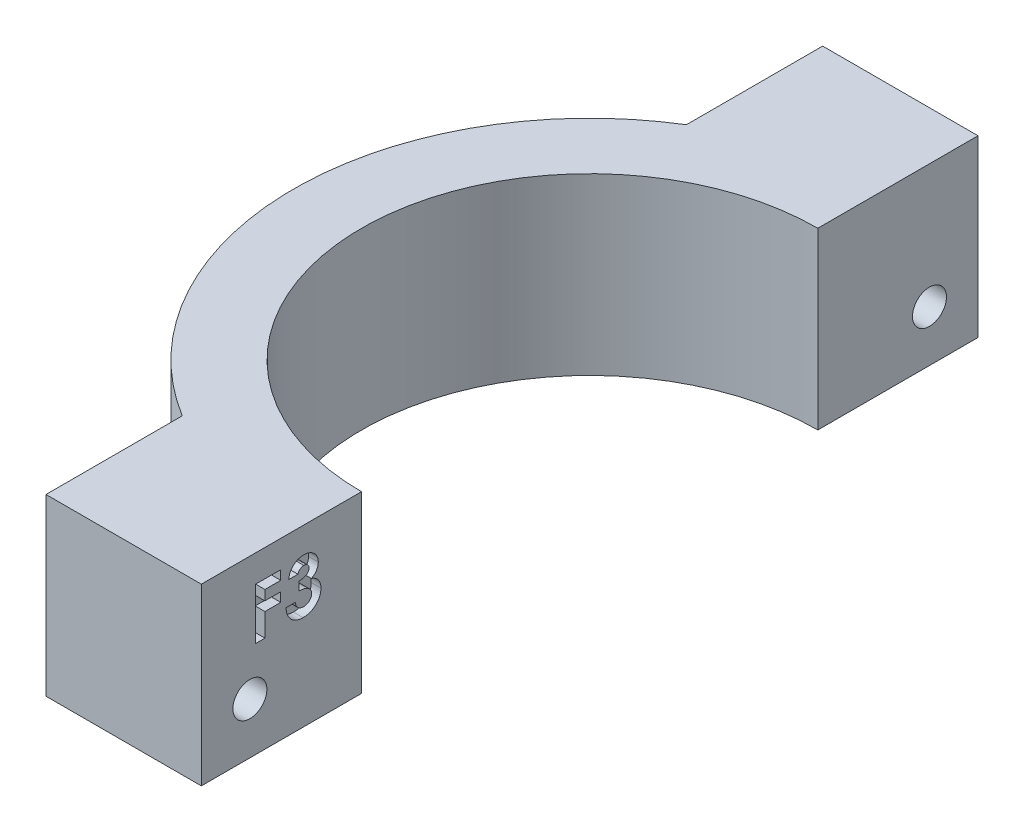
from build123d import *

# Parameters (mm, degrees)
BOSS_EXTRUDE1_DEPTH = 18
SKETCH2_R           = 1.75
CUT_EXTRUDE1_DEPTH  = 31.5
CUT_EXTRUDE2_DEPTH  = 1
CUT_EXTRUDE3_DEPTH  = 5


with BuildPart() as part:
    # Sketch1 → Boss-Extrude1 (new body)
    with BuildSketch(Plane(origin=(0, 0, 0), x_dir=(1, 0, 0), z_dir=(0, 1, 0))):
        with BuildLine():
            Line((-16.998275301, 32.528571429), (-32.998275301, 32.528571429))
            Line((-32.998275301, 32.528571429), (-32.998275301, 18.494895774))
            ThreePointArc((-32.998275301, 18.494895774), (-47.498275301, -7.471428571), (-32.998275301, -33.437752917))
            Line((-32.998275301, -33.437752917), (-32.998275301, -47.471428571))
            Line((-32.998275301, -47.471428571), (-16.998275301, -47.471428571))
            Line((-16.998275301, -47.471428571), (-16.998275301, -30.971428571))
            ThreePointArc((-16.998275301, -30.971428571), (-40.498275301, -7.471428571), (-16.998275301, 16.028571429))
            Line((-16.998275301, 16.028571429), (-16.998275301, 32.528571429))
        make_face()
    extrude(amount=BOSS_EXTRUDE1_DEPTH)

    # Sketch2 → Cut-Extrude1 (cut, through all)
    with BuildSketch(Plane(origin=(-16.998275301, 0, 0), x_dir=(0, 0, -1), z_dir=(1, 0, 0))):
        with Locations((-42.471428571, 5.25)):
            Circle(SKETCH2_R)
        with Locations((27.528571429, 5.25)):
            Circle(SKETCH2_R)
    extrude(amount=-CUT_EXTRUDE1_DEPTH, mode=Mode.SUBTRACT)

    # Sketch3 → Cut-Extrude2 (cut)
    with BuildSketch(Plane(origin=(-16.998275301, 0, 0), x_dir=(0, 0, -1), z_dir=(1, 0, 0))):
        Polygon((-41.871148795, 15.201025034), (-39.293157342, 15.201025034), (-39.293157342, 14.251238709), (-40.92136247, 14.251238709), (-40.92136247, 13.233610504), (-39.293157342, 13.233610504), (-39.293157342, 12.283824179), (-40.92136247, 12.283824179), (-40.92136247, 9.909358367), (-41.871148795, 9.909358367), align=None)
        with BuildLine():
            Line((-37.529268453, 13.912029308), (-38.479054777, 13.912029308))
            add(Edge.make_bspline(
                [(-38.479054777, 13.912029308), (-38.472348925, 13.959505738), (-38.459202545, 14.052580134), (-38.427745016, 14.187328674), (-38.390118416, 14.315146885), (-38.34314353, 14.435629995), (-38.288049629, 14.548992623), (-38.225396959, 14.655623774), (-38.154508221, 14.755065768), (-38.100171252, 14.814970019), (-38.073063525, 14.844855162)],
                knots=[0, 0, 0, 0, 0.000143778, 0.000281867, 0.000414671, 0.000543215, 0.000669322, 0.0007924, 0.000913902, 0.001034861, 0.001034861, 0.001034861, 0.001034861], degree=3))
            add(Edge.make_bspline(
                [(-38.073063525, 14.844855162), (-38.033964221, 14.884286443), (-37.956903602, 14.962001353), (-37.82812627, 15.061545568), (-37.693143844, 15.147694317), (-37.549249192, 15.215993668), (-37.398681424, 15.27127408), (-37.240243172, 15.308406058), (-37.074581872, 15.333043453), (-36.961538875, 15.335470322), (-36.903851118, 15.336708795)],
                knots=[0, 0, 0, 0, 0.000166428, 0.000328012, 0.000487119, 0.000645947, 0.000804887, 0.000967376, 0.001133328, 0.001306272, 0.001306272, 0.001306272, 0.001306272], degree=3))
            add(Edge.make_bspline(
                [(-36.903851118, 15.336708795), (-36.852563734, 15.335498), (-36.751743072, 15.333117822), (-36.603562067, 15.314011042), (-36.462283879, 15.280499879), (-36.326415158, 15.236684784), (-36.197954088, 15.177067025), (-36.07406541, 15.107863497), (-35.958210577, 15.022982493), (-35.850118512, 14.927075501), (-35.750815335, 14.8233427), (-35.664818348, 14.712460867), (-35.590885195, 14.597391911), (-35.529974057, 14.477179826), (-35.483141668, 14.3516212), (-35.450638602, 14.221441367), (-35.429364556, 14.08692758), (-35.427245105, 13.99550037), (-35.426170162, 13.949130336)],
                knots=[0, 0, 0, 0, 0.000153836, 0.00030241, 0.000447173, 0.000588968, 0.00072986, 0.000871333, 0.001014032, 0.001159723, 0.001304436, 0.001444171, 0.001580024, 0.001714184, 0.00184768, 0.001981114, 0.002116187, 0.002255197, 0.002255197, 0.002255197, 0.002255197], degree=3))
            add(Edge.make_bspline(
                [(-35.426170162, 13.949130336), (-35.428376009, 13.89170491), (-35.432718642, 13.778651902), (-35.468353097, 13.613190424), (-35.524130708, 13.454979724), (-35.604706892, 13.306233407), (-35.705447645, 13.167356277), (-35.829053175, 13.042991412), (-35.972002875, 12.931188942), (-36.079317119, 12.87110628), (-36.134269788, 12.840339604)],
                knots=[0, 0, 0, 0, 0.00017212, 0.000338852, 0.000505492, 0.00067385, 0.000844528, 0.001018431, 0.001198237, 0.00138694, 0.00138694, 0.00138694, 0.00138694], degree=3))
            add(Edge.make_bspline(
                [(-36.134269788, 12.840339604), (-36.096551119, 12.827955771), (-36.022435626, 12.803622094), (-35.917089364, 12.755697192), (-35.816917106, 12.703323219), (-35.723643783, 12.642478468), (-35.636341679, 12.575623232), (-35.555542998, 12.502186007), (-35.480764986, 12.422326922), (-35.413228364, 12.335606781), (-35.353286974, 12.243412505), (-35.299504756, 12.147873726), (-35.255238993, 12.047541582), (-35.21774038, 11.943561934), (-35.189191072, 11.835000267), (-35.169089807, 11.722277248), (-35.157470783, 11.605650007), (-35.155698684, 11.526635122), (-35.154802641, 11.486682085)],
                knots=[0, 0, 0, 0, 0.000119012, 0.000233852, 0.000346714, 0.000457856, 0.00056747, 0.000676282, 0.000785032, 0.000895296, 0.001005549, 0.001114686, 0.001223822, 0.001334132, 0.001445978, 0.001560132, 0.001677317, 0.001797176, 0.001797176, 0.001797176, 0.001797176], degree=3))
            add(Edge.make_bspline(
                [(-35.154802641, 11.486682085), (-35.156619041, 11.427967343), (-35.160200611, 11.31219383), (-35.182970562, 11.141671293), (-35.225364107, 10.979093204), (-35.281135164, 10.822588857), (-35.355527701, 10.674178666), (-35.443075211, 10.53045682), (-35.55068869, 10.396407552), (-35.670282595, 10.268486948), (-35.803098598, 10.152187262), (-35.947092752, 10.051360668), (-36.09909875, 9.964833512), (-36.260078289, 9.8945883), (-36.429975443, 9.840491454), (-36.608411526, 9.801387759), (-36.796136276, 9.777463472), (-36.924273105, 9.774955464), (-36.989713498, 9.773674607)],
                knots=[0, 0, 0, 0, 0.000176169, 0.00034737, 0.00051474, 0.000679386, 0.000844836, 0.001011921, 0.001183269, 0.001359492, 0.001536793, 0.001711778, 0.001885991, 0.002060677, 0.00223768, 0.002420033, 0.00260805, 0.002804296, 0.002804296, 0.002804296, 0.002804296], degree=3))
            add(Edge.make_bspline(
                [(-36.989713498, 9.773674607), (-37.051619054, 9.775025054), (-37.172667177, 9.777665676), (-37.349725391, 9.800521596), (-37.518002464, 9.837390049), (-37.677927841, 9.889359191), (-37.828882784, 9.956754287), (-37.972236212, 10.037006724), (-38.105127537, 10.134745277), (-38.229037432, 10.245557842), (-38.341217201, 10.369883248), (-38.441479496, 10.504841559), (-38.527613517, 10.650945966), (-38.599972501, 10.80757225), (-38.657990763, 10.974995181), (-38.703755398, 11.152874295), (-38.735722744, 11.341557113), (-38.745458467, 11.471374906), (-38.750422299, 11.537563496)],
                knots=[0, 0, 0, 0, 0.000185653, 0.000363021, 0.000534566, 0.000701839, 0.000866512, 0.001029812, 0.001193709, 0.001360353, 0.001527707, 0.001695195, 0.001863902, 0.002035591, 0.002211932, 0.002394731, 0.002586078, 0.002785121, 0.002785121, 0.002785121, 0.002785121], degree=3))
            Line((-38.750422299, 11.537563496), (-37.800635974, 11.537563496))
            add(Edge.make_bspline(
                [(-37.800635974, 11.537563496), (-37.794617277, 11.504283004), (-37.782894287, 11.439460519), (-37.760029312, 11.345611971), (-37.730233061, 11.258983964), (-37.695781181, 11.178806552), (-37.658567964, 11.104027033), (-37.613605499, 11.037407199), (-37.564188399, 10.977138049), (-37.492879164, 10.905489419), (-37.3909377, 10.831873443), (-37.253282951, 10.767897658), (-37.100155079, 10.730399988), (-36.993103425, 10.725825387), (-36.937772058, 10.723460932)],
                knots=[0, 0, 0, 0, 0.000101453, 0.000197607, 0.000289457, 0.000375893, 0.000459333, 0.000539595, 0.000616416, 0.00069287, 0.00084235, 0.000990791, 0.001145821, 0.001311674, 0.001311674, 0.001311674, 0.001311674], degree=3))
            add(Edge.make_bspline(
                [(-36.937772058, 10.723460932), (-36.90841128, 10.72396442), (-36.850900082, 10.724950642), (-36.766424697, 10.735881586), (-36.685949998, 10.753884861), (-36.609326097, 10.778350644), (-36.536065202, 10.809020032), (-36.467567036, 10.848566373), (-36.402435434, 10.89454464), (-36.341378437, 10.946236417), (-36.284960514, 11.002561951), (-36.238017483, 11.06493291), (-36.19511495, 11.128312952), (-36.163383928, 11.196848623), (-36.135580716, 11.266851971), (-36.11856373, 11.340863899), (-36.105714684, 11.417331835), (-36.104967949, 11.469663134), (-36.104588966, 11.49622235)],
                knots=[0, 0, 0, 0, 8.804e-05, 0.00017245, 0.000255004, 0.000335125, 0.000413489, 0.000492771, 0.000571884, 0.000652369, 0.000732575, 0.000810392, 0.000886249, 0.00096163, 0.001036443, 0.001111772, 0.00118898, 0.001268546, 0.001268546, 0.001268546, 0.001268546], degree=3))
            add(Edge.make_bspline(
                [(-36.104588966, 11.49622235), (-36.105595096, 11.525269377), (-36.10759807, 11.583095353), (-36.123962582, 11.667480206), (-36.149805605, 11.748651634), (-36.18570472, 11.82625017), (-36.233643988, 11.899989803), (-36.290211789, 11.971349973), (-36.35986473, 12.036616511), (-36.436283336, 12.101130505), (-36.524898897, 12.15736725), (-36.621395711, 12.209265504), (-36.728309865, 12.250560491), (-36.843031489, 12.287444563), (-36.967730649, 12.314384117), (-37.101633011, 12.333944858), (-37.244522568, 12.348504799), (-37.343018198, 12.350593662), (-37.393584692, 12.35166606)],
                knots=[0, 0, 0, 0, 8.7084e-05, 0.000173364, 0.000256838, 0.000342201, 0.000428949, 0.000520167, 0.000614623, 0.000714788, 0.000819753, 0.000928812, 0.001042981, 0.001163003, 0.001290052, 0.001425126, 0.001568892, 0.001720568, 0.001720568, 0.001720568, 0.001720568], degree=3))
            Line((-37.393584692, 12.35166606), (-37.393584692, 13.233610504))
            add(Edge.make_bspline(
                [(-37.393584692, 13.233610504), (-37.330626399, 13.238972234), (-37.212843901, 13.249002968), (-37.049355478, 13.272460189), (-36.911719301, 13.303814627), (-36.796627281, 13.34164206), (-36.701062242, 13.390222338), (-36.617577152, 13.44385282), (-36.545675843, 13.506136787), (-36.484909592, 13.57521694), (-36.436298482, 13.649402546), (-36.40189437, 13.727540541), (-36.379175692, 13.80721324), (-36.377023099, 13.861706965), (-36.375956487, 13.888708661)],
                knots=[0, 0, 0, 0, 0.000189544, 0.000354599, 0.000494992, 0.000612655, 0.000716948, 0.000815736, 0.000909673, 0.001001315, 0.001090992, 0.001174513, 0.001256793, 0.001337606, 0.001337606, 0.001337606, 0.001337606], degree=3))
            add(Edge.make_bspline(
                [(-36.375956487, 13.888708661), (-36.377796698, 13.923159894), (-36.3813884, 13.990401408), (-36.409283508, 14.086638178), (-36.457706253, 14.172425283), (-36.522632653, 14.247582201), (-36.601747728, 14.310358892), (-36.694484465, 14.355933699), (-36.798830471, 14.382710933), (-36.872243509, 14.38548683), (-36.910211295, 14.38692247)],
                knots=[0, 0, 0, 0, 0.000103264, 0.00020155, 0.000297405, 0.00039663, 0.000497784, 0.000598286, 0.000704469, 0.000818208, 0.000818208, 0.000818208, 0.000818208], degree=3))
            add(Edge.make_bspline(
                [(-36.910211295, 14.38692247), (-36.944624824, 14.385228566), (-37.012911806, 14.381867343), (-37.112767812, 14.356780059), (-37.20759775, 14.314548739), (-37.295437959, 14.256314238), (-37.375020447, 14.18637707), (-37.440334709, 14.103551012), (-37.494660015, 14.012798316), (-37.517687082, 13.945750658), (-37.529268453, 13.912029308)],
                knots=[0, 0, 0, 0, 0.000103172, 0.000204725, 0.000306758, 0.000413189, 0.000519795, 0.000623097, 0.000728547, 0.000835248, 0.000835248, 0.000835248, 0.000835248], degree=3))
        make_face()
    extrude(amount=-CUT_EXTRUDE2_DEPTH, mode=Mode.SUBTRACT)

    # Sketch4 → Cut-Extrude3 (cut)
    with BuildSketch(Plane.ZY.offset(32.998275301)):
        Polygon((-25.528765418, 2.783401278), (-24.392531269, 5.748583447), (-26.39233728, 8.215182169), (-29.528377439, 7.716598722), (-30.664611588, 4.751416553), (-28.664805577, 2.284817831), align=None)
        Polygon((44.362800811, 2.699305117), (45.626081257, 5.612628966), (43.734709018, 8.163323849), (40.580056332, 7.800694883), (39.316775886, 4.887371034), (41.208148125, 2.336676151), align=None)
    extrude(amount=-CUT_EXTRUDE3_DEPTH, mode=Mode.SUBTRACT)


solid = part.part
